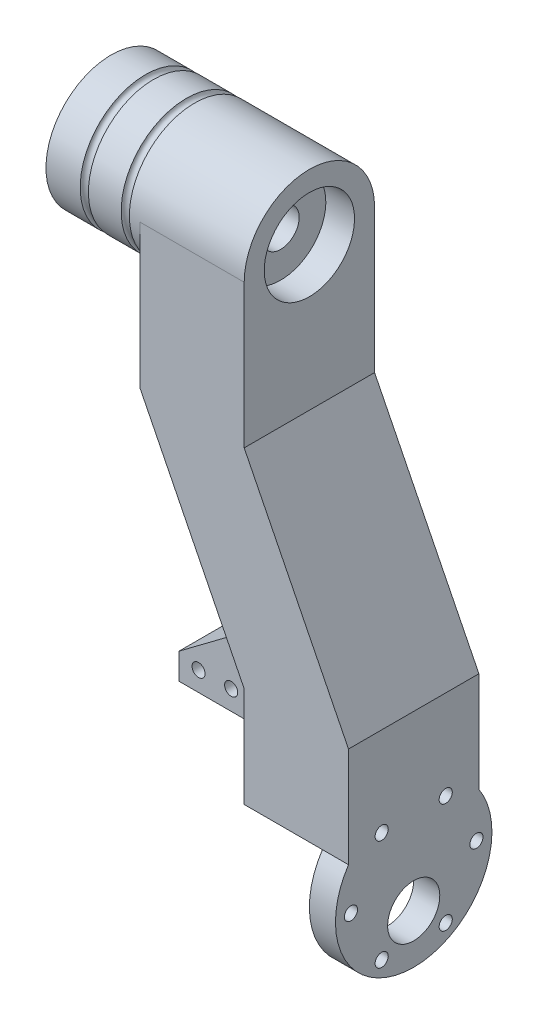
from build123d import *
from build123d.topology import SkipClean

# Parameters (mm, degrees)
SKETCH1_W           = 25.4
SKETCH1_H           = 50.8
BOSS_EXTRUDE1_DEPTH = 15.875
SKETCH2_R           = 4.5
CUT_EXTRUDE1_DEPTH  = 93.946735419
SKETCH3_R           = 15.875
SKETCH3_R_2         = 4.5
BOSS_EXTRUDE2_DEPTH = 22.86
SKETCH5_R           = 3.96875
CUT_EXTRUDE2_DEPTH  = 6.35
BOSS_EXTRUDE3_START = 3.81
SKETCH6_R           = 3.96875
SKETCH6_R_2         = 2.38125
BOSS_EXTRUDE3_DEPTH = 3.81
SKETCH8_R           = 19.05
BOSS_EXTRUDE4_DEPTH = 25.4
CUT_EXTRUDE3_START  = -19.05
SKETCH9_R           = 19.05
CUT_EXTRUDE3_DEPTH  = 19.05
SKETCH10_R          = 6.35
CUT_EXTRUDE4_DEPTH  = 19.05
F_3DSKETCH1_R       = 1.6
CUT_EXTRUDE5_DEPTH  = 25.4
SKETCH12_R          = 1.5875
BOSS_EXTRUDE5_DEPTH = 6.35
SKETCH13_R          = 10.99185
CUT_EXTRUDE6_DEPTH  = 6.985
CUT_EXTRUDE7_START  = -6.985
SKETCH14_R          = 10.99185
CUT_EXTRUDE7_DEPTH  = 6.985


with BuildPart() as part:
    # Sketch1 → Boss-Extrude1 (new, symmetric)
    with BuildSketch(Plane.XY):
        with Locations((-12.7, 50.8)):
            Rectangle(SKETCH1_W, SKETCH1_H)
        Polygon((0, 25.4), (25.4, -25.4), (0, -25.4), (-25.4, 25.4), align=None)
        with Locations((12.7, -50.8)):
            Rectangle(SKETCH1_W, SKETCH1_H)
    extrude(amount=BOSS_EXTRUDE1_DEPTH, both=True)

    # Sketch2 → Cut-Extrude1 (cut, through all)
    with BuildSketch(Plane(origin=(25.4, 0, 0), x_dir=(0, 0, -1), z_dir=(1, 0, 0))):
        with BuildLine():
            Line((-15.875, 76.2), (-15.875, 60.325))
            ThreePointArc((-15.875, 60.325), (-11.225320151, 71.550320151), (0, 76.2))
            Line((0, 76.2), (-15.875, 76.2))
        make_face()
        with BuildLine():
            Line((15.875, 76.2), (0, 76.2))
            ThreePointArc((0, 76.2), (11.225320151, 71.550320151), (15.875, 60.325))
            Line((15.875, 60.325), (15.875, 76.2))
        make_face()
        with Locations(Location((0, 60.325, 0), (0, 0, 90))):
            Circle(SKETCH2_R)
        with Locations(Location((0, -60.325, 0), (0, 0, 90))):
            Circle(SKETCH2_R)
        with BuildLine():
            ThreePointArc((-1.7e-08, -76.2), (-11.225320157, -71.550320145), (-15.875, -60.325))
            Line((-15.875, -60.325), (-15.875, -76.2))
            Line((-15.875, -76.2), (-1.7e-08, -76.2))
        make_face()
        with BuildLine():
            ThreePointArc((15.875, -60.325), (11.225320145, -71.550320157), (-1.7e-08, -76.2))
            Line((-1.7e-08, -76.2), (15.875, -76.2))
            Line((15.875, -76.2), (15.875, -60.325))
        make_face()
    extrude(amount=-CUT_EXTRUDE1_DEPTH, mode=Mode.SUBTRACT)

    # Sketch3 → Boss-Extrude2 (add)
    with SkipClean():  # the faces are left unmerged after this step: merging them gives an invalid solid
        with BuildSketch(Plane.ZY.offset(25.4)):
            with Locations(Location((0, 60.325, 0), (0, 0, 180))):
                Circle(SKETCH3_R)
            with Locations(Location((0, 60.325, 0), (0, 0, 270))):
                Circle(SKETCH3_R_2, mode=Mode.SUBTRACT)
        extrude(amount=BOSS_EXTRUDE2_DEPTH)

    # Sketch4 → Cut-Revolve1 (revolve, cut)
    with SkipClean():  # the faces are left unmerged after this step: merging them gives an invalid solid
        with BuildSketch(Plane.XY, mode=Mode.PRIVATE) as cut_revolve1_sk:
            with BuildLine():
                Line((-27.956, 76.2), (-29.956, 76.2))
                ThreePointArc((-29.956, 76.2), (-28.956, 75.2), (-27.956, 76.2))
            make_face()
            with BuildLine():
                Line((-39.9288, 76.2), (-37.9288, 76.2))
                ThreePointArc((-37.9288, 76.2), (-38.9288, 75.2), (-39.9288, 76.2))
            make_face()
        revolve(cut_revolve1_sk.sketch.rotate(Axis((-49.341870541, 60.325, 0), (1, 0, 0)), 90), axis=Axis((-49.341870541, 60.325, 0), (1, 0, 0)), mode=Mode.SUBTRACT)

    # Sketch5 → Cut-Extrude2 (cut)
    with SkipClean():  # the faces are left unmerged after this step: merging them gives an invalid solid
        with BuildSketch(Plane(origin=(0, 0, -15.875), x_dir=(-1, 0, 0), z_dir=(0, 0, -1))):
            with Locations((31.92475, 60.325)):
                Circle(SKETCH5_R)
            with Locations((41.89755, 60.325)):
                Circle(SKETCH5_R)
        extrude(amount=-CUT_EXTRUDE2_DEPTH, mode=Mode.SUBTRACT)

    # Sketch6 → Boss-Extrude3 (add)
    # profile 1 of 2: a face of its own
    with SkipClean():  # the faces are left unmerged after this step: merging them gives an invalid solid
        with BuildSketch(Plane(origin=(0, 0, -9.525), x_dir=(-1, 0, 0), z_dir=(0, 0, -1)).offset(BOSS_EXTRUDE3_START)):
            with Locations((31.92475, 60.325)):
                Circle(SKETCH6_R)
            with Locations(Location((31.92475, 60.325, 0), (0, 0, 180))):
                Circle(SKETCH6_R_2, mode=Mode.SUBTRACT)
        # profile 2 of 2: a face of its own
        with BuildSketch(Plane(origin=(0, 0, -9.525), x_dir=(-1, 0, 0), z_dir=(0, 0, -1)).offset(BOSS_EXTRUDE3_START)):
            with Locations((41.89755, 60.325)):
                Circle(SKETCH6_R)
            with Locations(Location((41.89755, 60.325, 0), (0, 0, 180))):
                Circle(SKETCH6_R_2, mode=Mode.SUBTRACT)
        extrude(amount=-BOSS_EXTRUDE3_DEPTH)

    # Sketch8 → Boss-Extrude4 (add)
    with SkipClean():  # the faces are left unmerged after this step: merging them gives an invalid solid
        with BuildSketch(Plane(origin=(25.4, 0, 0), x_dir=(0, 0, -1), z_dir=(1, 0, 0))):
            with Locations((0, -60.325)):
                Circle(SKETCH8_R)
        extrude(amount=-BOSS_EXTRUDE4_DEPTH)

    # Sketch9 → Cut-Extrude3 (cut)
    with SkipClean():  # the faces are left unmerged after this step: merging them gives an invalid solid
        with BuildSketch(Plane.ZY.offset(CUT_EXTRUDE3_START)):
            with Locations((0, -60.325)):
                Circle(SKETCH9_R)
        extrude(amount=CUT_EXTRUDE3_DEPTH, mode=Mode.SUBTRACT)

    # Sketch10 → Cut-Extrude4 (cut)
    with SkipClean():  # the faces are left unmerged after this step: merging them gives an invalid solid
        with BuildSketch(Plane.ZY.offset(-19.05)):
            with Locations(Location((0, -67.437, 0), (0, 0, 270))):
                Circle(SKETCH10_R)
        extrude(amount=-CUT_EXTRUDE4_DEPTH, mode=Mode.SUBTRACT)

    # 3DSketch1 → Cut-Extrude5 (cut)
    with SkipClean():  # the faces are left unmerged after this step: merging them gives an invalid solid
        with BuildSketch(Plane(origin=(19.05, -60.325, 15.2766), x_dir=(0, 0, -1), z_dir=(-1, 0, 0))):
            Circle(F_3DSKETCH1_R)
            with Locations((7.482370685, 13.567540858)):
                Circle(F_3DSKETCH1_R)
            with Locations((7.482370685, -13.214096537)):
                Circle(F_3DSKETCH1_R)
            with Locations((23.070829315, -13.214096537)):
                Circle(F_3DSKETCH1_R)
            with Locations((30.5532, 0)):
                Circle(F_3DSKETCH1_R)
            with Locations((23.070829315, 13.567540858)):
                Circle(F_3DSKETCH1_R)
        extrude(amount=-CUT_EXTRUDE5_DEPTH, mode=Mode.SUBTRACT)

    # Sketch12 → Boss-Extrude5 (add, symmetric)
    with SkipClean():  # the faces are left unmerged after this step: merging them gives an invalid solid
        with BuildSketch(Plane.XY):
            Polygon((0, -41.275), (-25.4, -41.275), (-25.4, -34.925), (0, -15.875), align=None)
            with Locations((-20.6375, -36.5125)):
                Circle(SKETCH12_R, mode=Mode.SUBTRACT)
            with Locations((-12.7, -36.5125)):
                Circle(SKETCH12_R, mode=Mode.SUBTRACT)
            with Locations((-4.7625, -36.5125)):
                Circle(SKETCH12_R, mode=Mode.SUBTRACT)
        extrude(amount=BOSS_EXTRUDE5_DEPTH, both=True)

    # Sketch13 → Cut-Extrude6 (cut)
    with SkipClean():  # the faces are left unmerged after this step: merging them gives an invalid solid
        with BuildSketch(Plane(origin=(0, 0, 0), x_dir=(0, 0, -1), z_dir=(1, 0, 0))):
            with Locations(Location((0, 60.325, 0), (0, 0, 90))):
                Circle(SKETCH13_R)
        extrude(amount=-CUT_EXTRUDE6_DEPTH, mode=Mode.SUBTRACT)

    # Sketch14 → Cut-Extrude7 (cut)
    with SkipClean():  # the faces are left unmerged after this step: merging them gives an invalid solid
        with BuildSketch(Plane.ZY.offset(48.26).offset(CUT_EXTRUDE7_START)):
            with Locations(Location((0, 60.325, 0), (0, 0, 90))):
                Circle(SKETCH14_R)
        extrude(amount=CUT_EXTRUDE7_DEPTH, mode=Mode.SUBTRACT)


solid = part.part
